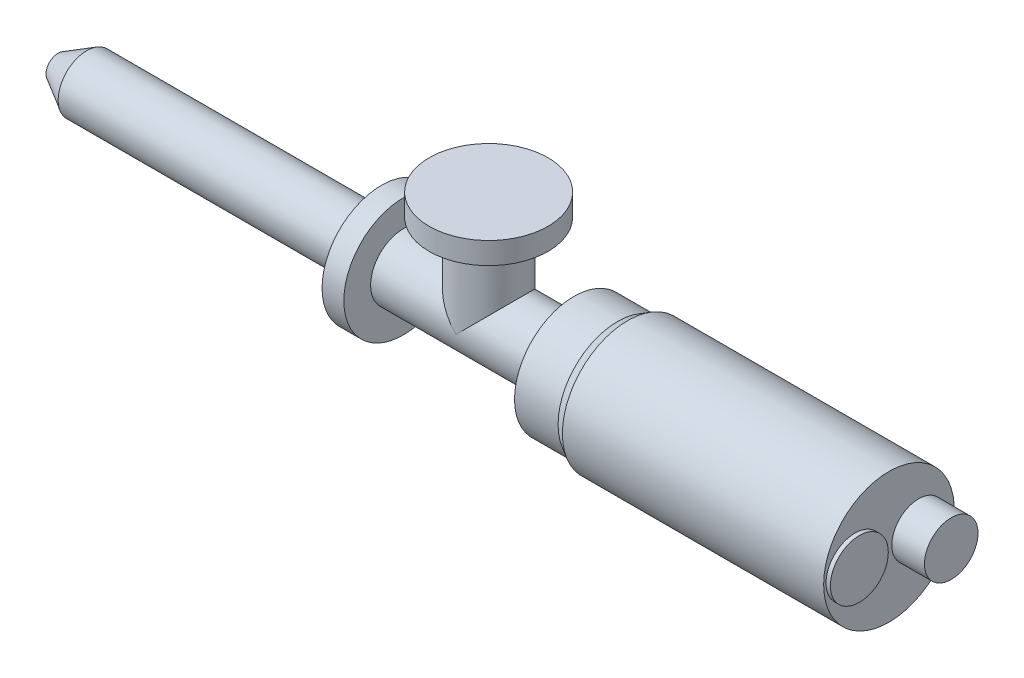
from build123d import *

# Parameters (mm, degrees)
SKETCH2_R           = 19.05
BOSS_EXTRUDE1_DEPTH = 62.484
SKETCH3_R           = 34.671
BOSS_EXTRUDE2_DEPTH = 12.7
SKETCH4_R           = 15.621
BOSS_EXTRUDE3_DEPTH = 19.05
SKETCH5_R           = 16.891
BOSS_EXTRUDE4_DEPTH = 2.54


with BuildPart() as part:
    # Sketch1 → Revolve1 (revolve)
    with BuildSketch(Plane.XY, mode=Mode.PRIVATE) as revolve1_sk:
        Polygon((0, 0), (0, 6.985), (16.761748485, 16.6624), (188.722, 16.6624), (188.722, 34.671), (201.422, 34.671), (201.422, 19.05), (300.99, 19.05), (300.99, 34.671), (326.39, 34.671), (332.329202219, 38.1), (484.729202219, 38.1), (484.729202219, 0), align=None)
    revolve(revolve1_sk.sketch.rotate(Axis((0, 0, 0), (1, 0, 0)), 90), axis=Axis((0, 0, 0), (1, 0, 0)))  # turned: the seam where the file's is

    # Sketch2 → Boss-Extrude1 (add)
    with BuildSketch(Plane(origin=(0, 0, 0), x_dir=(1, 0, 0), z_dir=(0, 1, 0))):
        with Locations(Location((251.206, 0, 0), (0, 0, 270))):  # turned: the seam where the file's is
            Circle(SKETCH2_R)
    extrude(amount=BOSS_EXTRUDE1_DEPTH)

    # Sketch3 → Boss-Extrude2 (add)
    with BuildSketch(Plane(origin=(0, 62.484, 0), x_dir=(1, 0, 0), z_dir=(0, 1, 0))):
        with Locations(Location((251.206, 0, 0), (0, 0, 270))):  # turned: the seam where the file's is
            Circle(SKETCH3_R)
    extrude(amount=-BOSS_EXTRUDE2_DEPTH)

    # Sketch4 → Boss-Extrude3 (add)
    with BuildSketch(Plane(origin=(484.729202219, 0, 0), x_dir=(0, 0, -1), z_dir=(1, 0, 0))):
        with Locations(Location((17.272, 0, 0), (0, 0, 180))):  # turned: the seam where the file's is
            Circle(SKETCH4_R)
    extrude(amount=BOSS_EXTRUDE3_DEPTH)

    # Sketch5 → Boss-Extrude4 (add)
    with BuildSketch(Plane(origin=(484.729202219, 0, 0), x_dir=(0, 0, -1), z_dir=(1, 0, 0))):
        with Locations(Location((-19.812, 0, 0), (0, 0, 180))):  # turned: the seam where the file's is
            Circle(SKETCH5_R)
    extrude(amount=BOSS_EXTRUDE4_DEPTH)


solid = part.part
